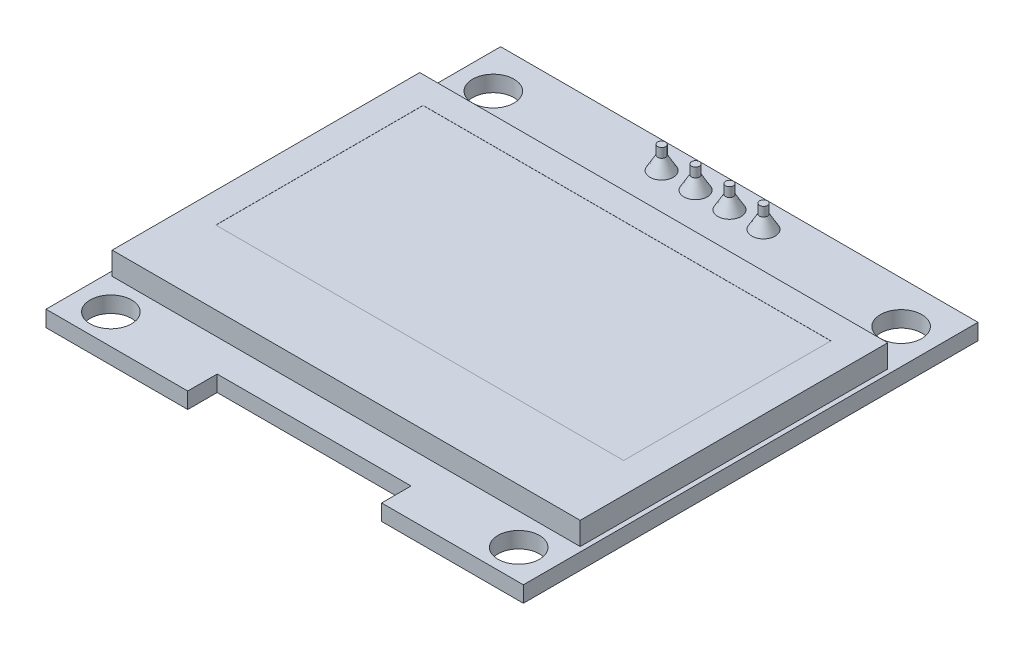
from build123d import *

# Parameters (mm, degrees)
SKIZZE1_W                       = 35.7
SKIZZE1_H                       = 34
AUFSATZ_LINEAR_AUSTRAGEN1_DEPTH = 1.2
SKIZZE2_R                       = 1.55
SCHNITT_LINEAR_AUSTRAGEN1_DEPTH = 2.2
SKIZZE3_W                       = 35
SKIZZE3_H                       = 23
AUFSATZ_LINEAR_AUSTRAGEN2_DEPTH = 1.7
SKIZZE4_W                       = 30.5
SKIZZE4_H                       = 15.5
SCHNITT_LINEAR_AUSTRAGEN2_DEPTH = 0.01
SKIZZE5_W                       = 14.5
SKIZZE5_H                       = 2.2
SCHNITT_LINEAR_AUSTRAGEN3_DEPTH = 2.2
SKIZZE6_R                       = 0.875
AUFSATZ_LINEAR_AUSTRAGEN3_DEPTH = 1
AUFSATZ_LINEAR_AUSTRAGEN3_TAPER = 30
SKIZZE7_R                       = 0.297649731
AUFSATZ_LINEAR_AUSTRAGEN4_DEPTH = 0.7
SKIZZE8_R                       = 0.297649731
AUFSATZ_LINEAR_AUSTRAGEN5_DEPTH = 8.5
SKIZZE9_W                       = 10.1
SKIZZE9_H                       = 2.54
AUFSATZ_LINEAR_AUSTRAGEN6_DEPTH = 1.8


with BuildPart() as part:
    # Skizze1 → Aufsatz-Linear austragen1 (new body)
    with BuildSketch(Plane(origin=(0, 0, 0), x_dir=(1, 0, 0), z_dir=(0, 1, 0))):
        Rectangle(SKIZZE1_W, SKIZZE1_H)
    extrude(amount=AUFSATZ_LINEAR_AUSTRAGEN1_DEPTH)

    # Skizze2 → Schnitt-Linear austragen1 (cut, through all)
    with BuildSketch(Plane(origin=(0, 1.2, 0), x_dir=(1, 0, 0), z_dir=(0, 1, 0))):
        with Locations((-15.25, 13.85)):
            Circle(SKIZZE2_R)
        with Locations((15.25, 13.85)):
            Circle(SKIZZE2_R)
        with Locations((15.25, -14.75)):
            Circle(SKIZZE2_R)
        with Locations((-15.25, -14.75)):
            Circle(SKIZZE2_R)
    extrude(amount=-SCHNITT_LINEAR_AUSTRAGEN1_DEPTH, mode=Mode.SUBTRACT)

    # Skizze3 → Aufsatz-Linear austragen2 (add)
    with BuildSketch(Plane(origin=(0, 1.2, 0), x_dir=(1, 0, 0), z_dir=(0, 1, 0))):
        with Locations((0, -0.9)):
            Rectangle(SKIZZE3_W, SKIZZE3_H)
    extrude(amount=AUFSATZ_LINEAR_AUSTRAGEN2_DEPTH)

    # Skizze4 → Schnitt-Linear austragen2 (cut)
    with BuildSketch(Plane(origin=(0, 2.9, 0), x_dir=(1, 0, 0), z_dir=(0, 1, 0))):
        with Locations((0, 0.85)):
            Rectangle(SKIZZE4_W, SKIZZE4_H)
    extrude(amount=-SCHNITT_LINEAR_AUSTRAGEN2_DEPTH, mode=Mode.SUBTRACT)

    # Skizze5 → Schnitt-Linear austragen3 (cut, through all)
    with BuildSketch(Plane(origin=(0, 1.2, 0), x_dir=(1, 0, 0), z_dir=(0, 1, 0))):
        with Locations((0, -15.9)):
            Rectangle(SKIZZE5_W, SKIZZE5_H)
    extrude(amount=-SCHNITT_LINEAR_AUSTRAGEN3_DEPTH, mode=Mode.SUBTRACT)

    # Skizze6 → Aufsatz-Linear austragen3 (add)
    with BuildSketch(Plane(origin=(0, 1.2, 0), x_dir=(1, 0, 0), z_dir=(0, 1, 0))):
        with Locations((-3.81, 15)):
            Circle(SKIZZE6_R)
        with Locations((3.81, 15)):
            Circle(SKIZZE6_R)
        with Locations((1.27, 15)):
            Circle(SKIZZE6_R)
        with Locations((-1.27, 15)):
            Circle(SKIZZE6_R)
    extrude(amount=AUFSATZ_LINEAR_AUSTRAGEN3_DEPTH, taper=AUFSATZ_LINEAR_AUSTRAGEN3_TAPER)

    # Skizze7 → Aufsatz-Linear austragen4 (add)
    with BuildSketch(Plane(origin=(0, 2.2, 0), x_dir=(1, 0, 0), z_dir=(0, 1, 0))):
        with Locations((-3.81, 15)):
            Circle(SKIZZE7_R)
        with Locations((-1.27, 15)):
            Circle(SKIZZE7_R)
        with Locations((1.27, 15)):
            Circle(SKIZZE7_R)
        with Locations((3.81, 15)):
            Circle(SKIZZE7_R)
    extrude(amount=AUFSATZ_LINEAR_AUSTRAGEN4_DEPTH)

    # Skizze8 → Aufsatz-Linear austragen5 (add)
    with BuildSketch(Plane.XZ):
        with Locations((-1.27, -15)):
            Circle(SKIZZE8_R)
        with Locations((-3.81, -15)):
            Circle(SKIZZE8_R)
        with Locations((1.27, -15)):
            Circle(SKIZZE8_R)
        with Locations((3.81, -15)):
            Circle(SKIZZE8_R)
    extrude(amount=AUFSATZ_LINEAR_AUSTRAGEN5_DEPTH)


with BuildPart() as body_2:
    # Skizze9 → Aufsatz-Linear austragen6 (new body)
    with BuildSketch(Plane.XZ):
        with Locations((0, -15)):
            Rectangle(SKIZZE9_W, SKIZZE9_H)
    extrude(amount=AUFSATZ_LINEAR_AUSTRAGEN6_DEPTH)


solid = Compound([part.part, body_2.part])
